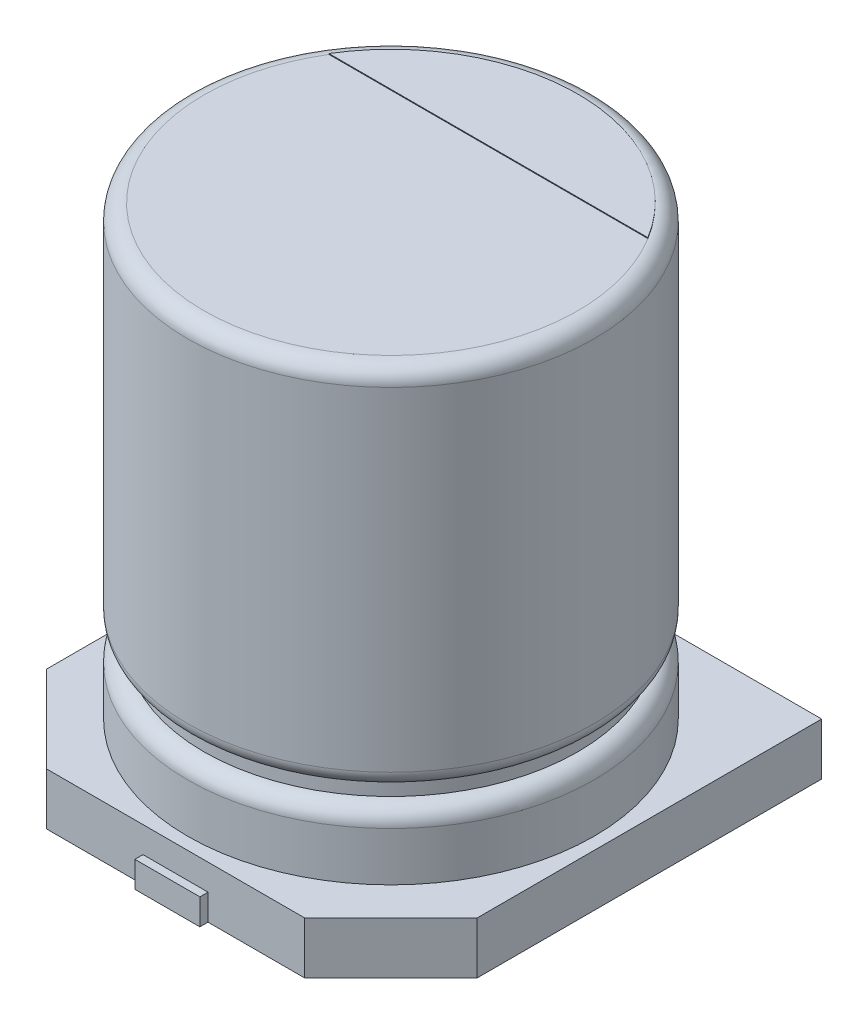
from build123d import *

# Parameters (mm, degrees)
BOSS_EXTRUDE1_DEPTH = 0.01
BOSS_EXTRUDE2_DEPTH = 0.64
CUT_EXTRUDE1_START  = 0.64
CUT_EXTRUDE1_DEPTH  = 0.32
SKETCH4_W           = 0.8
SKETCH4_H           = 2.25
BOSS_EXTRUDE3_DEPTH = 0.32


with BuildPart() as part:
    # Sketch1 → Revolve1 (revolve)
    with BuildSketch(Plane.XY):
        with BuildLine():
            Line((0, 5.5), (-2.3, 5.5))
            ThreePointArc((-2.3, 5.5), (-2.441421356, 5.441421356), (-2.5, 5.3))
            Line((-2.5, 5.3), (-2.5, 1.2))
            ThreePointArc((-2.5, 1.2), (-2.441421356, 1.058578644), (-2.3, 1))
            Line((-2.3, 1), (-2.3, 0.8))
            ThreePointArc((-2.3, 0.8), (-2.441421356, 0.741421356), (-2.5, 0.6))
            Line((-2.5, 0.6), (-2.5, 0))
            Line((-2.5, 0), (0, 0))
            Line((0, 0), (0, 5.5))
        make_face()
    revolve(axis=Axis((0, 8.082229881, 0), (0, -1, 0)))

    # Sketch2 → Boss-Extrude1 (add)
    with BuildSketch(Plane(origin=(0, 5.5, 0), x_dir=(1, 0, 0), z_dir=(0, 1, 0))):
        with BuildLine():
            Line((-1.962141687, 1.2), (1.962141687, 1.2))
            ThreePointArc((1.962141687, 1.2), (0, 2.3), (-1.962141687, 1.2))
        make_face()
    extrude(amount=BOSS_EXTRUDE1_DEPTH)

    # Sketch3 → Boss-Extrude2 (add)
    with BuildSketch(Plane(origin=(0, 0, 0), x_dir=(-1, 0, 0), z_dir=(0, -1, 0))):
        Polygon((1.589339828, -2.65), (2.65, -1.589339828), (2.65, 2.65), (-2.65, 2.65), (-2.65, -1.589339828), (-1.589339828, -2.65), align=None)
    extrude(amount=BOSS_EXTRUDE2_DEPTH)

    # Sketch3_3 → Cut-Extrude1 (cut)
    with BuildSketch(Plane(origin=(0, 0, 0), x_dir=(-1, 0, 0), z_dir=(0, -1, 0)).offset(CUT_EXTRUDE1_START)):
        with BuildLine():
            Line((0.4, 0.5), (0.4, 2.467792536))
            ThreePointArc((0.4, 2.467792536), (0, 2.5), (-0.4, 2.467792536))
            Line((-0.4, 2.467792536), (-0.4, 0.5))
            Line((-0.4, 0.5), (0.4, 0.5))
        make_face()
        with BuildLine():
            ThreePointArc((-0.4, -2.467792536), (0, -2.5), (0.4, -2.467792536))
            Line((0.4, -2.467792536), (0.4, -0.5))
            Line((0.4, -0.5), (-0.4, -0.5))
            Line((-0.4, -0.5), (-0.4, -2.467792536))
        make_face()
        with BuildLine():
            Line((0.4, 2.467792536), (0.4, 2.65))
            Line((0.4, 2.65), (-0.4, 2.65))
            Line((-0.4, 2.65), (-0.4, 2.467792536))
            ThreePointArc((-0.4, 2.467792536), (0, 2.5), (0.4, 2.467792536))
        make_face()
        with BuildLine():
            Line((-0.4, -2.65), (0.4, -2.65))
            Line((0.4, -2.65), (0.4, -2.467792536))
            ThreePointArc((0.4, -2.467792536), (0, -2.5), (-0.4, -2.467792536))
            Line((-0.4, -2.467792536), (-0.4, -2.65))
        make_face()
    extrude(amount=-CUT_EXTRUDE1_DEPTH, mode=Mode.SUBTRACT)

    # Sketch4 → Boss-Extrude3 (add)
    with BuildSketch(Plane.XZ.offset(0.32)):
        with Locations((0, -1.625)):
            Rectangle(SKETCH4_W, SKETCH4_H)
        with Locations((0, 1.625)):
            Rectangle(SKETCH4_W, SKETCH4_H)
    extrude(amount=BOSS_EXTRUDE3_DEPTH)


solid = part.part
